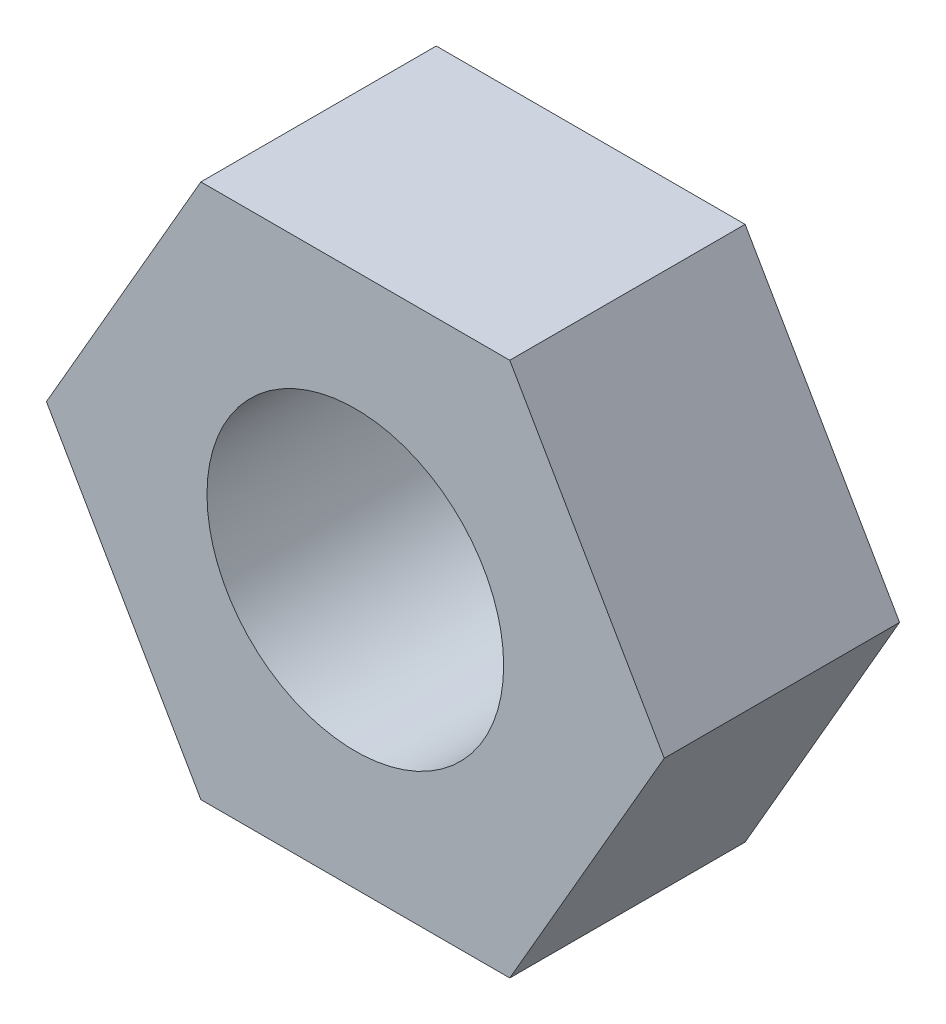
from build123d import *

# Parameters (mm, degrees)
SKETCH1_R           = 1.5
BOSS_EXTRUDE1_DEPTH = 2.38


with BuildPart() as part:
    # Sketch1 → Boss-Extrude1 (new body)
    with BuildSketch(Plane.XY):
        Polygon((1.561732478, -2.705), (3.123464956, 0), (1.561732478, 2.705), (-1.561732478, 2.705), (-3.123464956, 0), (-1.561732478, -2.705), align=None)
        Circle(SKETCH1_R, mode=Mode.SUBTRACT)
    extrude(amount=BOSS_EXTRUDE1_DEPTH)


solid = part.part
